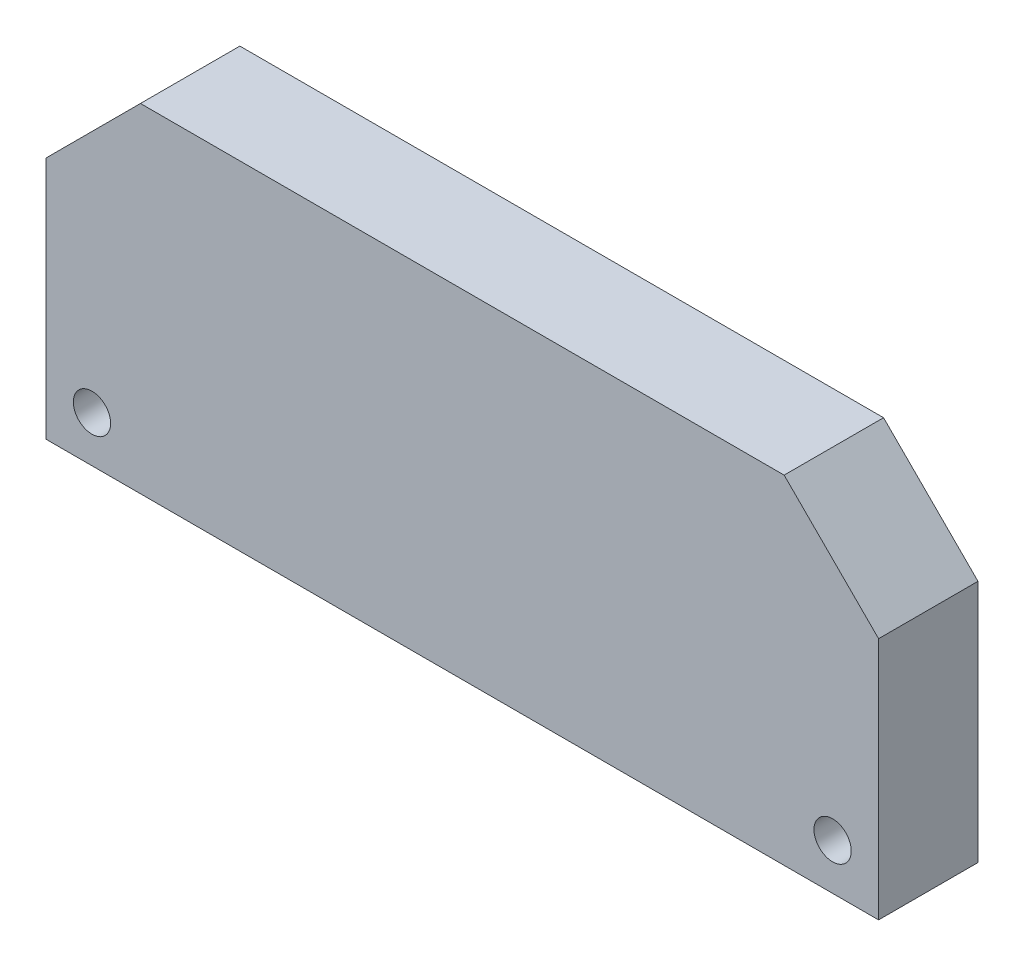
from build123d import *

# Parameters (mm, degrees)
SKETCH1_W           = 67
SKETCH1_H           = 27.2
BOSS_EXTRUDE1_DEPTH = 8
SKETCH3_R           = 1.5
CUT_EXTRUDE1_DEPTH  = 8
CHAMFER1_SIZE       = 7.6


with BuildPart() as part:
    # Sketch1 → Boss-Extrude1 (new body)
    with BuildSketch(Plane.XY):
        Rectangle(SKETCH1_W, SKETCH1_H)
    extrude(amount=BOSS_EXTRUDE1_DEPTH)

    # Sketch3 → Cut-Extrude1 (cut)
    with BuildSketch(Plane.XY.offset(8)):
        with Locations((29.8, -9.9)):
            Circle(SKETCH3_R)
        with Locations((-29.8, -9.9)):
            Circle(SKETCH3_R)
    extrude(amount=-CUT_EXTRUDE1_DEPTH, mode=Mode.SUBTRACT)

    # Chamfer1
    chamfer1_edges = [part.edges().sort_by_distance(p)[0] for p in [
        (-33.5, 13.6, 4),
        (33.5, 13.6, 4),
    ]]
    chamfer(chamfer1_edges, length=CHAMFER1_SIZE)


solid = part.part
